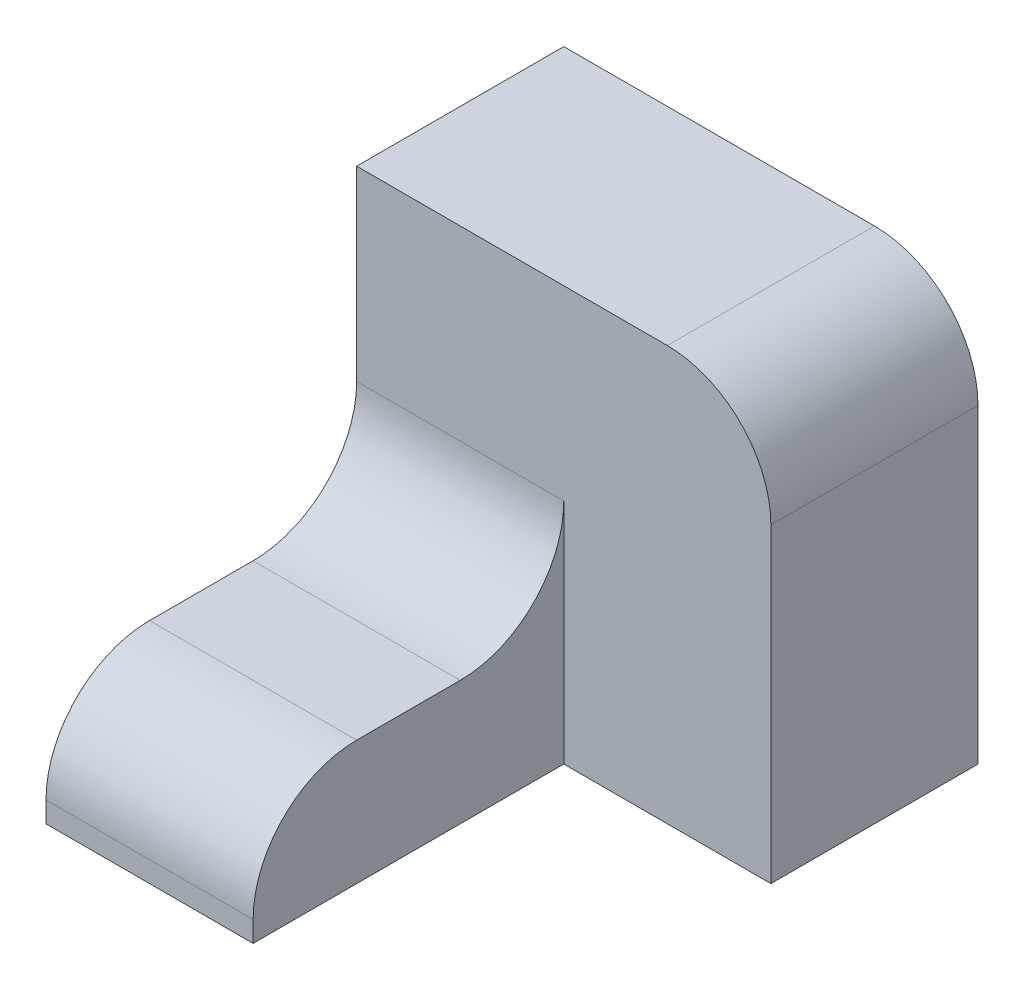
from build123d import *

# Parameters (mm, degrees)
SKETCH1_W           = 20
SKETCH1_H           = 12
BOSS_EXTRUDE1_DEPTH = 30
SKETCH2_W           = 40
SKETCH2_H           = 40
BOSS_EXTRUDE2_DEPTH = 20
FILLET1_R           = 10


with BuildPart() as part:
    # Sketch1 → Boss-Extrude1 (new body)
    with BuildSketch(Plane.XY):
        with Locations((-20, -6)):
            Rectangle(SKETCH1_W, SKETCH1_H)
    extrude(amount=BOSS_EXTRUDE1_DEPTH)

    # Sketch2 → Boss-Extrude2 (add)
    with BuildSketch(Plane.XY):
        with Locations((-10, 8)):
            Rectangle(SKETCH2_W, SKETCH2_H)
    extrude(amount=-BOSS_EXTRUDE2_DEPTH)

    # Fillet1
    fillet1_edges = [part.edges().sort_by_distance(p)[0] for p in [
        (10, 28, -10),
        (-20, 0, 30),
        (-20, 0, 0),
    ]]
    fillet(fillet1_edges, radius=FILLET1_R)


solid = part.part
